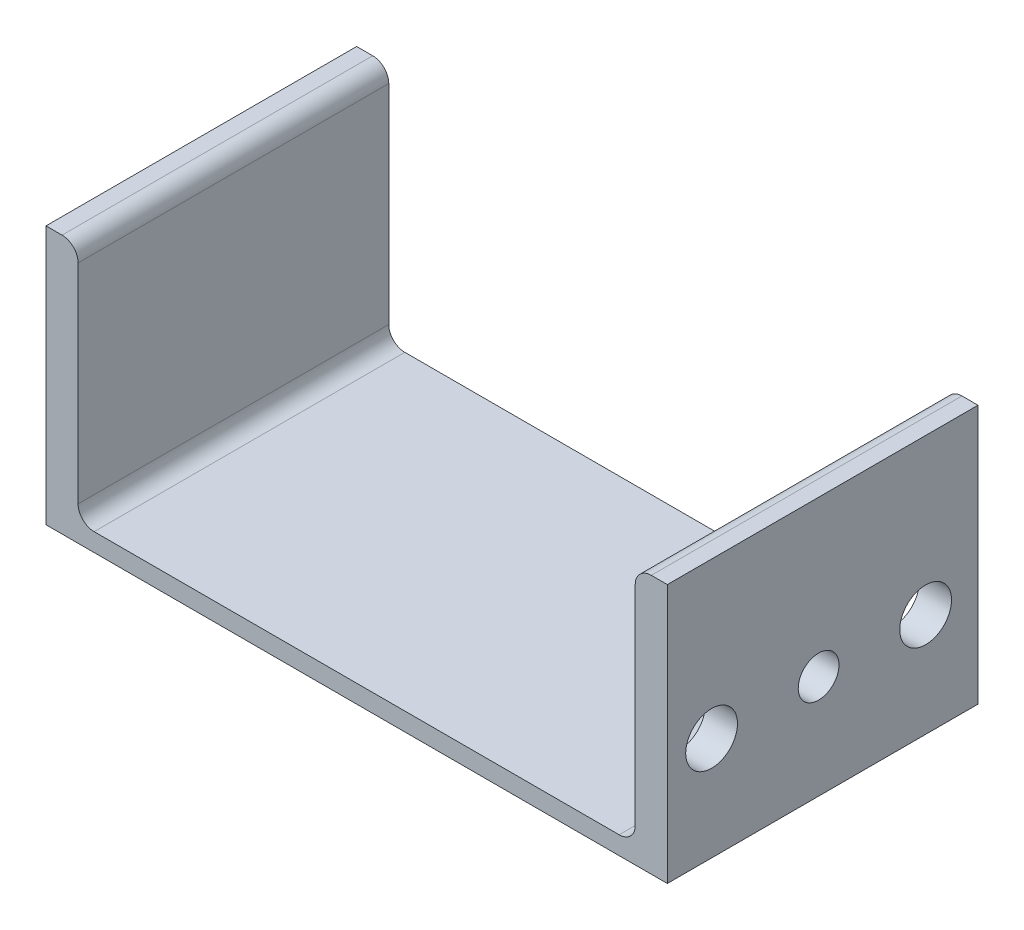
from build123d import *

# Parameters (mm, degrees)
BOSS_EXTRUDE1_DEPTH = 76.2
FILLET1_R           = 7.874
SKETCH3_R           = 12.7
SKETCH3_R_2         = 10
CUT_EXTRUDE1_DEPTH  = 15.748


with BuildPart() as part:
    # Sketch1 → Boss-Extrude1 (new body, symmetric)
    with BuildSketch(Plane.XY):
        Polygon((-136.652, 127), (-152.4, 127), (-152.4, 0), (152.4, 0), (152.4, 127), (136.652, 127), (136.652, 8.89), (-136.652, 8.89), align=None)
    extrude(amount=BOSS_EXTRUDE1_DEPTH, both=True)

    # Fillet1
    fillet1_edges = [part.edges().sort_by_distance(p)[0] for p in [
        (-136.652, 8.89, 0),
        (136.652, 8.89, 0),
        (136.652, 127, 0),
        (-136.652, 127, 0),
    ]]
    fillet(fillet1_edges, radius=FILLET1_R)

    # Sketch3 → Cut-Extrude1 (cut)
    with BuildSketch(Plane(origin=(152.4, 0, 0), x_dir=(0, 0, -1), z_dir=(1, 0, 0))):
        with Locations((50.506866673, 50.8)):
            Circle(SKETCH3_R)
        with Locations((-54.493133327, 50.8)):
            Circle(SKETCH3_R)
        with Locations((-1.993133327, 50.8)):
            Circle(SKETCH3_R_2)
    extrude(amount=-CUT_EXTRUDE1_DEPTH, mode=Mode.SUBTRACT)


solid = part.part
